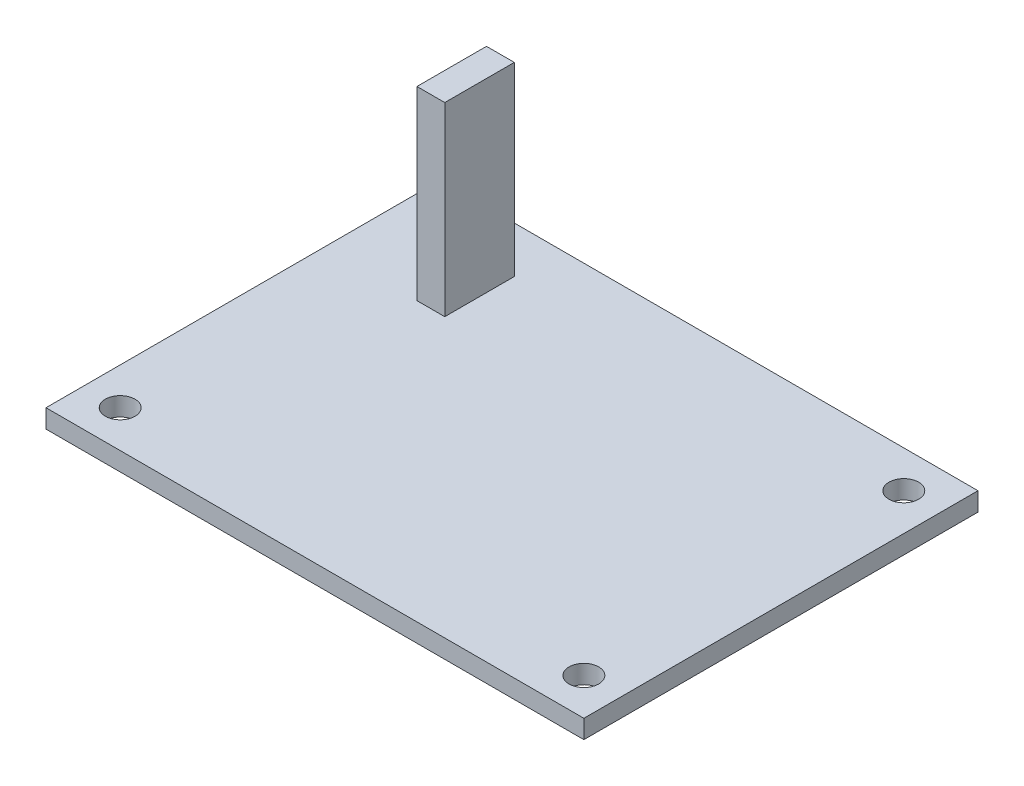
from build123d import *

# Parameters (mm, degrees)
SKETCH_1_W          = 58
SKETCH_1_H          = 42.5
EXTRUDE_1_DEPTH     = 2
SKETCH_2_R          = 1.6
CUT_EXTRUDE_1_DEPTH = 3
SKETCH_3_W          = 3
SKETCH_3_H          = 7.5
EXTRUDE_2_DEPTH     = 20


with BuildPart() as part:
    # 草图1 → 凸台-拉伸1 (new body)
    with BuildSketch(Plane(origin=(0, 0, 0), x_dir=(1, 0, 0), z_dir=(0, 1, 0))):
        with Locations((29, 21.25)):
            Rectangle(SKETCH_1_W, SKETCH_1_H)
    extrude(amount=EXTRUDE_1_DEPTH)

    # 草图2 → 切除-拉伸1 (cut, through all)
    with BuildSketch(Plane(origin=(0, 2, 0), x_dir=(1, 0, 0), z_dir=(0, 1, 0))):
        with Locations((54, 38.5)):
            Circle(SKETCH_2_R)
        with Locations((54, 4)):
            Circle(SKETCH_2_R)
        with Locations((4, 4)):
            Circle(SKETCH_2_R)
        with Locations((4, 38.5)):
            Circle(SKETCH_2_R)
    extrude(amount=-CUT_EXTRUDE_1_DEPTH, mode=Mode.SUBTRACT)

    # 草图3 → 凸台-拉伸2 (add)
    with BuildSketch(Plane(origin=(0, 2, 0), x_dir=(1, 0, 0), z_dir=(0, 1, 0))):
        with Locations((11.5, 33.75)):
            Rectangle(SKETCH_3_W, SKETCH_3_H)
    extrude(amount=EXTRUDE_2_DEPTH)


solid = part.part
